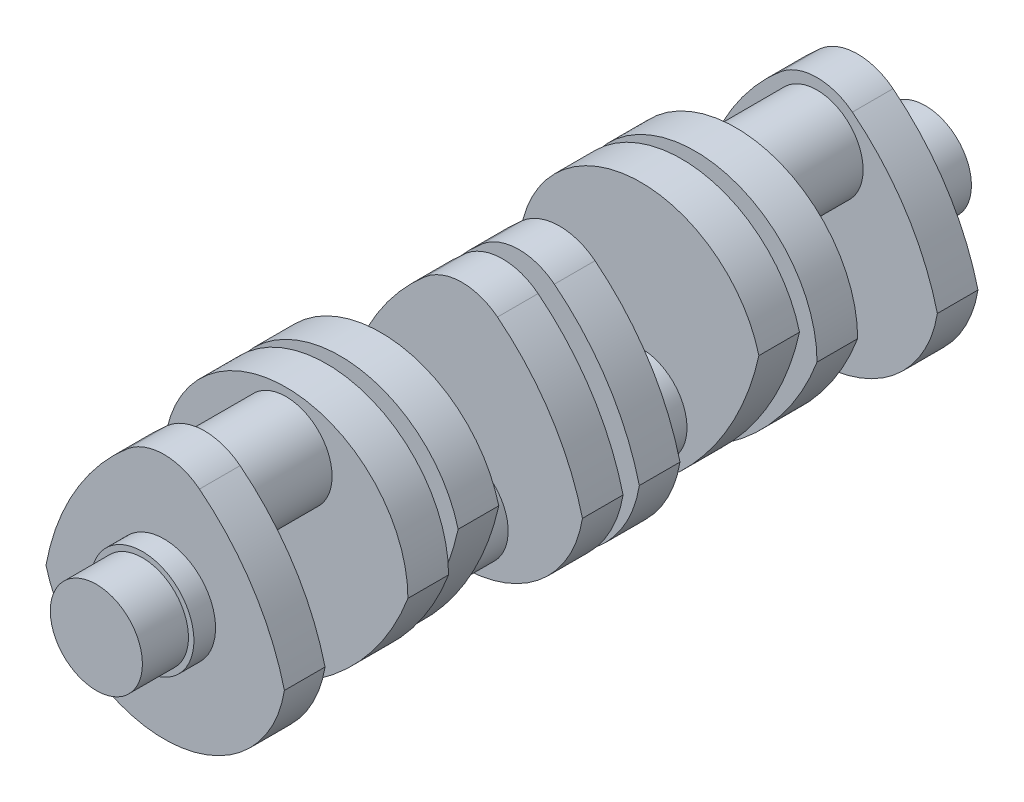
from build123d import *

# Parameters (mm, degrees)
IZIM1_R                      = 17
Y_KSEKLIK_EKSTR_ZYON1_DEPTH  = 25
IZIM2_R                      = 19
Y_KSEKLIK_EKSTR_ZYON2_DEPTH  = 8
Y_KSEKLIK_EKSTR_ZYON3_DEPTH  = 15
IZIM4_R                      = 17
Y_KSEKLIK_EKSTR_ZYON4_DEPTH  = 30
Y_KSEKLIK_EKSTR_ZYON5_DEPTH  = 15
IZIM6_R                      = 17
Y_KSEKLIK_EKSTR_ZYON6_DEPTH  = 5
Y_KSEKLIK_EKSTR_ZYON7_DEPTH  = 15
IZIM9_R                      = 17
Y_KSEKLIK_EKSTR_ZYON8_DEPTH  = 30
Y_KSEKLIK_EKSTR_ZYON9_DEPTH  = 15
IZIM12_R                     = 17
Y_KSEKLIK_EKSTR_ZYON10_DEPTH = 3


with BuildPart() as part:
    # Çizim1 → Yükseklik-Ekstrüzyon1 (new body)
    with BuildSketch(Plane.XY):
        Circle(IZIM1_R)
    extrude(amount=Y_KSEKLIK_EKSTR_ZYON1_DEPTH)

    # Çizim2 → Yükseklik-Ekstrüzyon2 (add)
    with BuildSketch(Plane(origin=(0, 0, 0), x_dir=(-1, 0, 0), z_dir=(0, 0, -1))):
        Circle(IZIM2_R)
    extrude(amount=-Y_KSEKLIK_EKSTR_ZYON2_DEPTH)

    # Çizim3 → Yükseklik-Ekstrüzyon3 (add)
    with BuildSketch(Plane(origin=(0, 0, 0), x_dir=(-1, 0, 0), z_dir=(0, 0, -1))):
        with BuildLine():
            ThreePointArc((-44.415603771, -7.228702626), (-2.027811095, -44.954287695), (43.584396229, -11.198232242))
            ThreePointArc((43.584396229, -11.198232242), (33.112866367, 17.436067755), (13.682042331, 40.931155566))
            ThreePointArc((13.682042331, 40.931155566), (0.405418694, 45.996086199), (-13.05683546, 41.447463263))
            ThreePointArc((-13.05683546, 41.447463263), (-32.757662874, 19.700124785), (-44.415603771, -7.228702626))
        make_face()
    extrude(amount=Y_KSEKLIK_EKSTR_ZYON3_DEPTH)

    # Çizim4 → Yükseklik-Ekstrüzyon4 (add)
    with BuildSketch(Plane(origin=(0, 0, -15), x_dir=(-1, 0, 0), z_dir=(0, 0, -1))):
        with Locations((0, 25)):
            Circle(IZIM4_R)
    extrude(amount=Y_KSEKLIK_EKSTR_ZYON4_DEPTH)

    # Çizim5 → Yükseklik-Ekstrüzyon5 (add)
    with BuildSketch(Plane(origin=(0, 0, -45), x_dir=(-1, 0, 0), z_dir=(0, 0, -1))):
        with BuildLine():
            ThreePointArc((45, 0), (0, 45), (-45, 0))
            ThreePointArc((-45, 0), (-31.68561215, -23.649975334), (-11.926296118, -42.255449988))
            ThreePointArc((-11.926296118, -42.255449988), (0, -45.97067458), (11.926296118, -42.255449988))
            ThreePointArc((11.926296118, -42.255449988), (31.68561215, -23.649975334), (45, 0))
        make_face()
    extrude(amount=Y_KSEKLIK_EKSTR_ZYON5_DEPTH)

    # Çizim6 → Yükseklik-Ekstrüzyon6 (add)
    with BuildSketch(Plane(origin=(0, 0, -60), x_dir=(-1, 0, 0), z_dir=(0, 0, -1))):
        Circle(IZIM6_R)
    extrude(amount=Y_KSEKLIK_EKSTR_ZYON6_DEPTH)

    # Çizim7 → Yükseklik-Ekstrüzyon7 (add)
    with BuildSketch(Plane(origin=(0, 0, -65), x_dir=(-1, 0, 0), z_dir=(0, 0, -1))):
        with BuildLine():
            ThreePointArc((44.457488298, 6.966472151), (2.243897169, 44.944019908), (-43.542511702, 11.360003287))
            ThreePointArc((-43.542511702, 11.360003287), (-32.842453707, -16.531076412), (-14.546498608, -40.145936031))
            ThreePointArc((-14.546498608, -40.145936031), (1.83841745, -45.919374304), (16.965213719, -37.376652353))
            ThreePointArc((16.965213719, -37.376652353), (33.480341406, -16.921835259), (44.457488298, 6.966472151))
        make_face()
    extrude(amount=Y_KSEKLIK_EKSTR_ZYON7_DEPTH)

    # Çizim9 → Yükseklik-Ekstrüzyon8 (add)
    with BuildSketch(Plane(origin=(0, 0, -80), x_dir=(-1, 0, 0), z_dir=(0, 0, -1))):
        with Locations((0, -25)):
            Circle(IZIM9_R)
    extrude(amount=Y_KSEKLIK_EKSTR_ZYON8_DEPTH)

    # Çizim10 → Yükseklik-Ekstrüzyon9 (add)
    with BuildSketch(Plane(origin=(0, 0, -110), x_dir=(-1, 0, 0), z_dir=(0, 0, -1))):
        with BuildLine():
            ThreePointArc((-44.415603771, -7.228702626), (-2.027811095, -44.954287695), (43.584396229, -11.198232242))
            ThreePointArc((43.584396229, -11.198232242), (33.112866367, 17.436067755), (13.682042331, 40.931155566))
            ThreePointArc((13.682042331, 40.931155566), (0.405418694, 45.996086199), (-13.05683546, 41.447463263))
            ThreePointArc((-13.05683546, 41.447463263), (-32.757662874, 19.700124785), (-44.415603771, -7.228702626))
        make_face()
    extrude(amount=Y_KSEKLIK_EKSTR_ZYON9_DEPTH)

    # Çizim12 → Yükseklik-Ekstrüzyon10 (add)
    with BuildSketch(Plane(origin=(0, 0, -125), x_dir=(-1, 0, 0), z_dir=(0, 0, -1))):
        Circle(IZIM12_R)
    extrude(amount=Y_KSEKLIK_EKSTR_ZYON10_DEPTH)

    # Aynalama1: part across plane


with BuildPart() as part_1:
    add(part.part)
    add(part.part.mirror(Plane(origin=(0, 0, -128), x_dir=(1, 0, 0), z_dir=(0, 0, -1))))


solid = part_1.part
